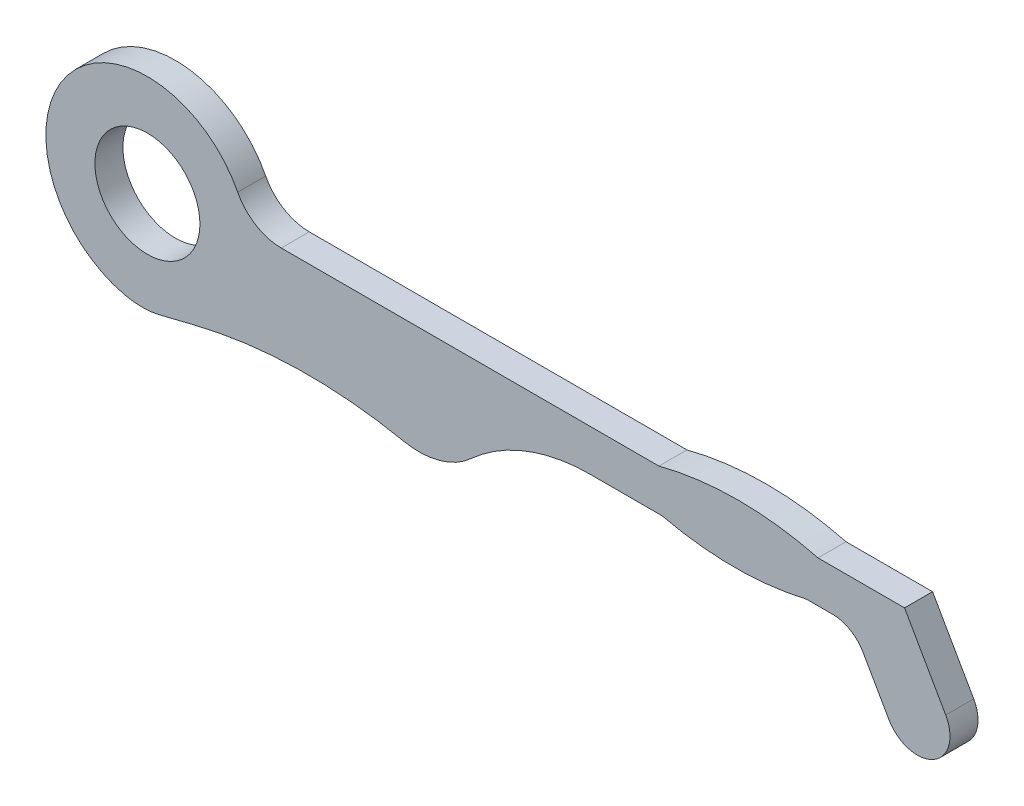
from build123d import *

# Parameters (mm, degrees)
BOSS_EXTRUDE1_DEPTH = 0.4
CUT_EXTRUDE1_REACH  = 2.4
SKETCH2_R           = 0.75
FILLET1_R           = 0.5
FILLET2_R           = 0.7
FILLET3_R           = 1.1


with BuildPart() as part:
    # Sketch1 → Boss-Extrude1 (new body)
    with BuildSketch(Plane.XY):
        with BuildLine():
            Line((11.400711478, -0.747727009), (10.812582712, 0.284))
            Line((10.812582712, 0.284), (9.577065579, 0.284))
            ThreePointArc((9.577065579, 0.284), (8.441, 0.429), (7.304934421, 0.284))
            Line((7.304934421, 0.284), (1.421915609, 0.284))
            ThreePointArc((1.421915609, 0.284), (-1.127957488, 0.911159648), (0.021323855, -1.449843196))
            Line((0.021323855, -1.449843196), (0.658996505, -1.291597308))
            ThreePointArc((0.658996505, -1.291597308), (2.462224804, -1.094137246), (4.253267655, -1.381866782))
            ThreePointArc((4.253267655, -1.381866782), (5.15625108, -0.593183537), (6.321, -0.309))
            Line((6.321, -0.309), (7.350233295, -0.309))
            ThreePointArc((7.350233295, -0.309), (8.381, -0.429), (9.411766705, -0.309))
            Line((9.411766705, -0.309), (10.075524156, -0.309))
            Line((10.075524156, -0.309), (10.589288522, -1.210272991))
            ThreePointArc((10.589288522, -1.210272991), (11.226272991, -1.384711478), (11.400711478, -0.747727009))
        make_face()
    extrude(amount=BOSS_EXTRUDE1_DEPTH)

    # Sketch2 → Cut-Extrude1 (cut, up to next)
    with BuildSketch(Plane.XY, mode=Mode.PRIVATE) as cut_extrude1_sk1:
        Circle(SKETCH2_R)
    cut_extrude1_tool1 = extrude(cut_extrude1_sk1.sketch, amount=CUT_EXTRUDE1_REACH, mode=Mode.PRIVATE) & part.part
    add(cut_extrude1_tool1.solids().sort_by_distance((0, 0, 0))[0], mode=Mode.SUBTRACT)

    # Fillet1
    fillet1_edges = [part.edges().sort_by_distance(p)[0] for p in [
        (10.075524156, -0.309, 0.2),
    ]]
    fillet(fillet1_edges, radius=FILLET1_R)

    # Fillet2
    fillet2_edges = [part.edges().sort_by_distance(p)[0] for p in [
        (1.421915609, 0.284, 0.2),
    ]]
    fillet(fillet2_edges, radius=FILLET2_R)

    # Fillet3
    fillet3_edges = [part.edges().sort_by_distance(p)[0] for p in [
        (0.021323855, -1.449843196, 0.2),
        (4.253267655, -1.381866782, 0.2),
    ]]
    fillet(fillet3_edges, radius=FILLET3_R)


solid = part.part
